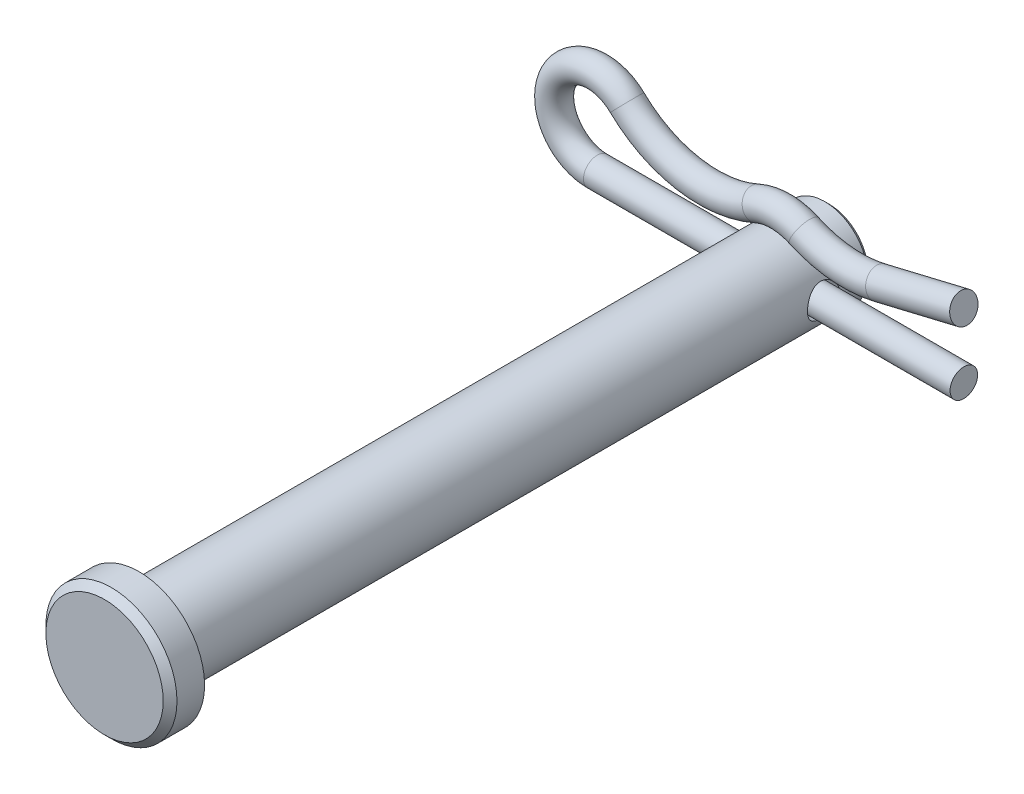
from build123d import *

# Parameters (mm, degrees)
SKETCH1_R           = 3.175
EXTRUDE1_DEPTH      = 25.4
SKETCH2_R           = 4.826
EXTRUDE2_DEPTH      = 2.54
CHAMFER1_SIZE       = 0.508
SKETCH3_R           = 1.190625
EXTRUDE3_DEPTH      = 5.826
EXTRUDE3_DEPTH_BACK = 5.826
CHAMFER2_SIZE       = 0.3175
SKETCH7_R           = 1.016


with BuildPart() as part:
    # Sketch1 → Extrude1 (new body, symmetric)
    with BuildSketch(Plane.XY):
        Circle(SKETCH1_R)
    extrude(amount=EXTRUDE1_DEPTH, both=True)

    # Sketch2 → Extrude2 (add)
    with BuildSketch(Plane.XY.offset(25.4)):
        Circle(SKETCH2_R)
    extrude(amount=EXTRUDE2_DEPTH)

    # Chamfer1
    chamfer1_edges = [part.edges().sort_by_distance(p)[0] for p in [
        (-4.826, 0, 27.94),
    ]]
    chamfer(chamfer1_edges, length=CHAMFER1_SIZE)

    # Sketch3 → Extrude3 (cut, two sides)
    with BuildSketch(Plane(origin=(0, 0, 0), x_dir=(0, 0, -1), z_dir=(1, 0, 0))) as extrude3_sk:
        with Locations((21.828125, 0)):
            Circle(SKETCH3_R)
    extrude(amount=EXTRUDE3_DEPTH, mode=Mode.SUBTRACT)
    extrude(extrude3_sk.sketch, amount=-EXTRUDE3_DEPTH_BACK, mode=Mode.SUBTRACT)

    # Chamfer2
    chamfer2_edges = [part.edges().sort_by_distance(p)[0] for p in [
        (-3.175, 0, -25.4),
    ]]
    chamfer(chamfer2_edges, length=CHAMFER2_SIZE)


with BuildPart() as body_2:
    # Sweep1: sweep along a path in Sketch6
    with BuildLine(Plane.XY.offset(-21.828125)) as sweep1_path:
        Line((13.49375, 0), (-13.49375, 0))
        ThreePointArc((-13.49375, 0), (-16.438801729, 4.361294783), (-11.292994408, 5.463514764))
        ThreePointArc((-11.292994408, 5.463514764), (-6.763179694, 3.173261299), (-1.728419774, 3.817989796))
        ThreePointArc((-1.728419774, 3.817989796), (0, 4.191), (1.728419774, 3.817989796))
        ThreePointArc((1.728419774, 3.817989796), (4.472851559, 3.087280395), (7.306026778, 3.28466386))
        Line((7.306026778, 3.28466386), (13.49375, 4.7625))
    # Sketch7 → Sweep1 (sweep)
    with BuildSketch(Plane(origin=(13.49375, 0, -21.828125), x_dir=(0, 0, 1), z_dir=(-1, 0, 0))):
        Circle(SKETCH7_R)
    sweep(path=sweep1_path.line)


solid = Compound([part.part, body_2.part])
